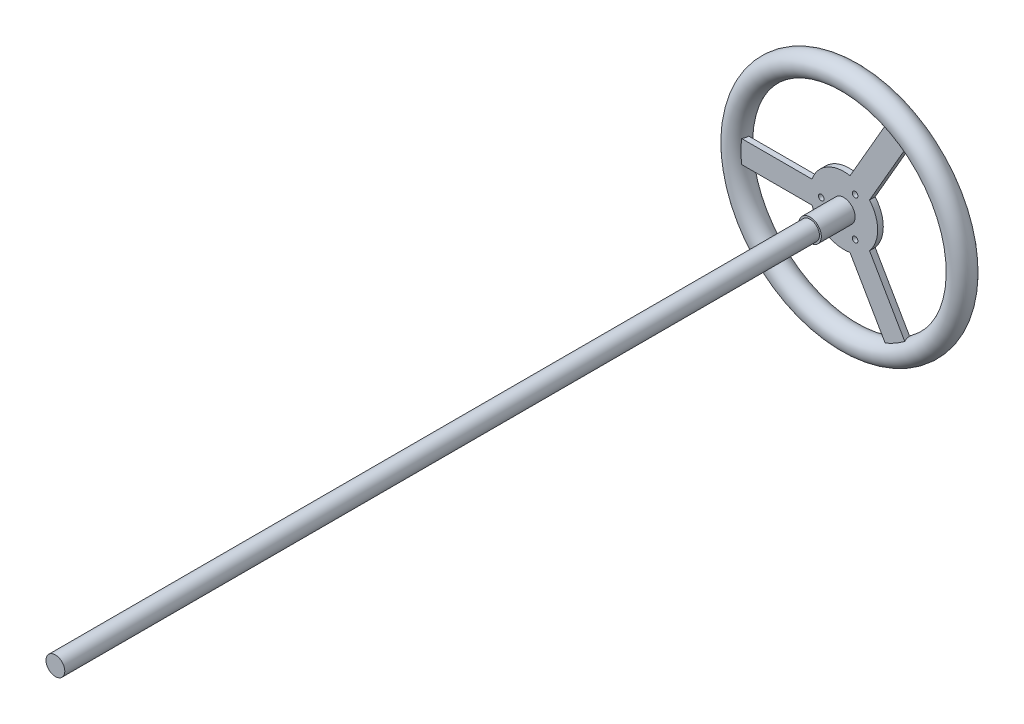
from build123d import *

# Parameters (mm, degrees)
SKETCH3_R           = 30
SKETCH3_R_2         = 2.5
BOSS_EXTRUDE1_DEPTH = 5
SKETCH4_R           = 8.35
BOSS_EXTRUDE2_DEPTH = 700
SKETCH6_R           = 10
BOSS_EXTRUDE3_DEPTH = 30
BOSS_EXTRUDE4_DEPTH = 5
SKETCH11_R          = 10


with BuildPart() as part:
    # Sketch3 → Boss-Extrude1 (new body)
    with BuildSketch(Plane.XY):
        Circle(SKETCH3_R)
        with Locations((-20, 0)):
            Circle(SKETCH3_R_2, mode=Mode.SUBTRACT)
        with Locations((10, 17.320508076)):
            Circle(SKETCH3_R_2, mode=Mode.SUBTRACT)
        with Locations((10, -17.320508076)):
            Circle(SKETCH3_R_2, mode=Mode.SUBTRACT)
    extrude(amount=BOSS_EXTRUDE1_DEPTH)

    # Sketch4 → Boss-Extrude2 (add)
    with BuildSketch(Plane.XY.offset(5)):
        Circle(SKETCH4_R)
    extrude(amount=BOSS_EXTRUDE2_DEPTH)

    # Sketch6 → Boss-Extrude3 (add)
    with BuildSketch(Plane.XY.offset(5)):
        Circle(SKETCH6_R)
    extrude(amount=BOSS_EXTRUDE3_DEPTH)

    # Sketch8 → Boss-Extrude4 (add)
    with BuildSketch(Plane(origin=(0, 0, 0), x_dir=(-1, 0, 0), z_dir=(0, 0, -1))):
        with BuildLine():
            Line((-58.409625893, 81.168439698), (-22.802389662, 19.494897428))
            ThreePointArc((-22.802389662, 19.494897428), (-15, 25.980762114), (-5.481881586, 29.494897428))
            Line((-5.481881586, 29.494897428), (-41.089117817, 91.168439698))
            ThreePointArc((-41.089117817, 91.168439698), (-50, 86.602540378), (-58.409625893, 81.168439698))
        make_face()
        with BuildLine():
            Line((28.284271247, -10), (99.498743711, -10))
            ThreePointArc((99.498743711, -10), (99.874607311, -5.006277506), (100, 0))
            ThreePointArc((100, 0), (99.874607311, 5.006277506), (99.498743711, 10))
            Line((99.498743711, 10), (28.284271247, 10))
            ThreePointArc((28.284271247, 10), (29.56795679, 5.073059362), (30, 0))
            ThreePointArc((30, 0), (29.56795679, -5.073059362), (28.284271247, -10))
        make_face()
        with BuildLine():
            ThreePointArc((-58.409625893, -81.168439698), (-50, -86.602540378), (-41.089117817, -91.168439698))
            Line((-41.089117817, -91.168439698), (-5.481881586, -29.494897428))
            ThreePointArc((-5.481881586, -29.494897428), (-15, -25.980762114), (-22.802389662, -19.494897428))
            Line((-22.802389662, -19.494897428), (-58.409625893, -81.168439698))
        make_face()
    extrude(amount=-BOSS_EXTRUDE4_DEPTH)

    # Sweep1: sweep along a path in Sketch10
    with BuildLine(Plane(origin=(0, 0, 0), x_dir=(-1, 0, 0), z_dir=(0, 0, -1))) as sweep1_path:
        CenterArc((0, 0), 100, 0, 360)
    # Sketch11 → Sweep1 (sweep)
    with BuildSketch(Plane(origin=(0, 0, 0), x_dir=(1, 0, 0), z_dir=(0, 1, 0))):
        with Locations((100, 0)):
            Circle(SKETCH11_R)
    sweep(path=sweep1_path.line)


solid = part.part
